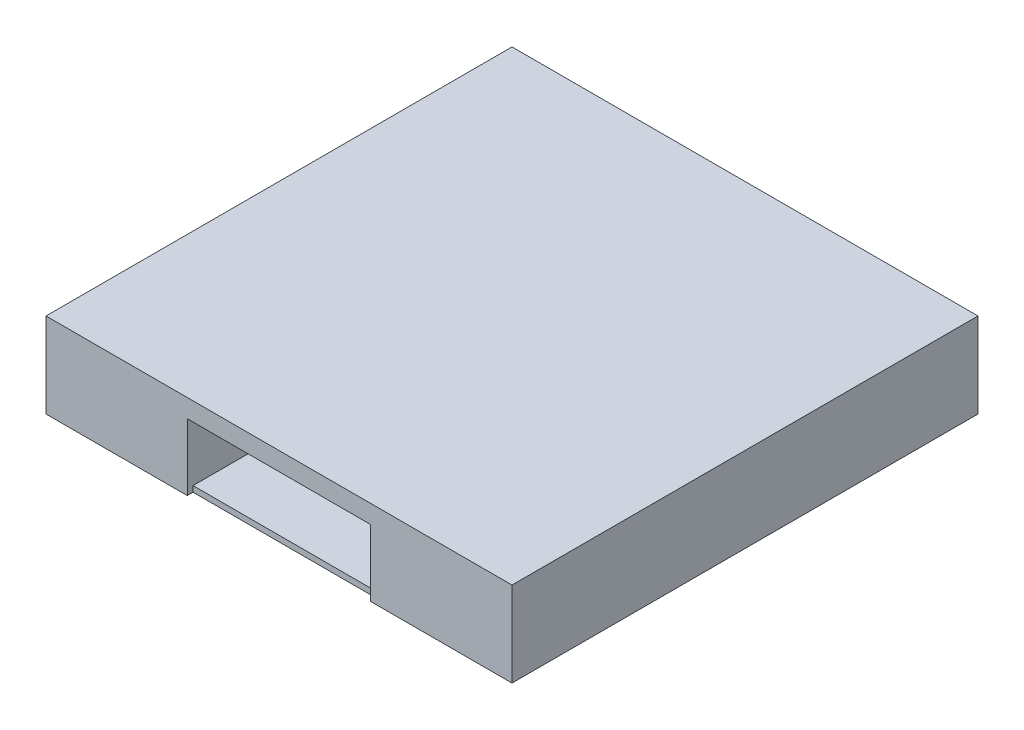
from build123d import *

# Parameters (mm, degrees)
SKETCH3_W               = 508
SKETCH3_H               = 508
BOSS_EXTRUDE1_DEPTH     = 6.3
SKETCH4_W               = 508
SKETCH4_H               = 508
SKETCH4_W_2             = 495.4
SKETCH4_H_2             = 495.4
BOSS_EXTRUDE2_DEPTH     = 80
SKETCH5_W               = 508
SKETCH5_H               = 508
BOSS_EXTRUDE3_DEPTH     = 6.3
SKETCH6_W               = 200
SKETCH6_H               = 72.6
CUT_EXTRUDE2_DEPTH      = 1
CUT_EXTRUDE2_DEPTH_BACK = 6.3
SKETCH8_W               = 6.3
SKETCH8_H               = 92.6
BOSS_EXTRUDE4_DEPTH     = 508


with BuildPart() as part:
    # Sketch3 → Boss-Extrude1 (new body)
    with BuildSketch(Plane(origin=(0, 0, 0), x_dir=(1, 0, 0), z_dir=(0, 1, 0))):
        with Locations((254, 254)):
            Rectangle(SKETCH3_W, SKETCH3_H)
    extrude(amount=BOSS_EXTRUDE1_DEPTH)

    # Sketch4 → Boss-Extrude2 (add)
    with BuildSketch(Plane(origin=(0, 6.3, 0), x_dir=(1, 0, 0), z_dir=(0, 1, 0))):
        with Locations((254, 254)):
            Rectangle(SKETCH4_W, SKETCH4_H)
        with Locations((254, 254)):
            Rectangle(SKETCH4_W_2, SKETCH4_H_2, mode=Mode.SUBTRACT)
    extrude(amount=BOSS_EXTRUDE2_DEPTH)

    # Sketch5 → Boss-Extrude3 (add)
    with BuildSketch(Plane(origin=(0, 86.3, 0), x_dir=(1, 0, 0), z_dir=(0, 1, 0))):
        with Locations((254, 254)):
            Rectangle(SKETCH5_W, SKETCH5_H)
    extrude(amount=BOSS_EXTRUDE3_DEPTH)

    # Sketch6 → Cut-Extrude2 (cut, two sides)
    with BuildSketch(Plane.XY) as cut_extrude2_sk:
        with Locations((254, 36.3)):
            Rectangle(SKETCH6_W, SKETCH6_H)
    extrude(amount=CUT_EXTRUDE2_DEPTH, mode=Mode.SUBTRACT)
    extrude(cut_extrude2_sk.sketch, amount=-CUT_EXTRUDE2_DEPTH_BACK, mode=Mode.SUBTRACT)

    # Sketch8 → Boss-Extrude4 (add)
    with BuildSketch(Plane.XY):
        with Locations((150.85, 46.3)):
            Rectangle(SKETCH8_W, SKETCH8_H)
        with Locations((357.15, 46.3)):
            Rectangle(SKETCH8_W, SKETCH8_H)
    extrude(amount=-BOSS_EXTRUDE4_DEPTH)


solid = part.part
